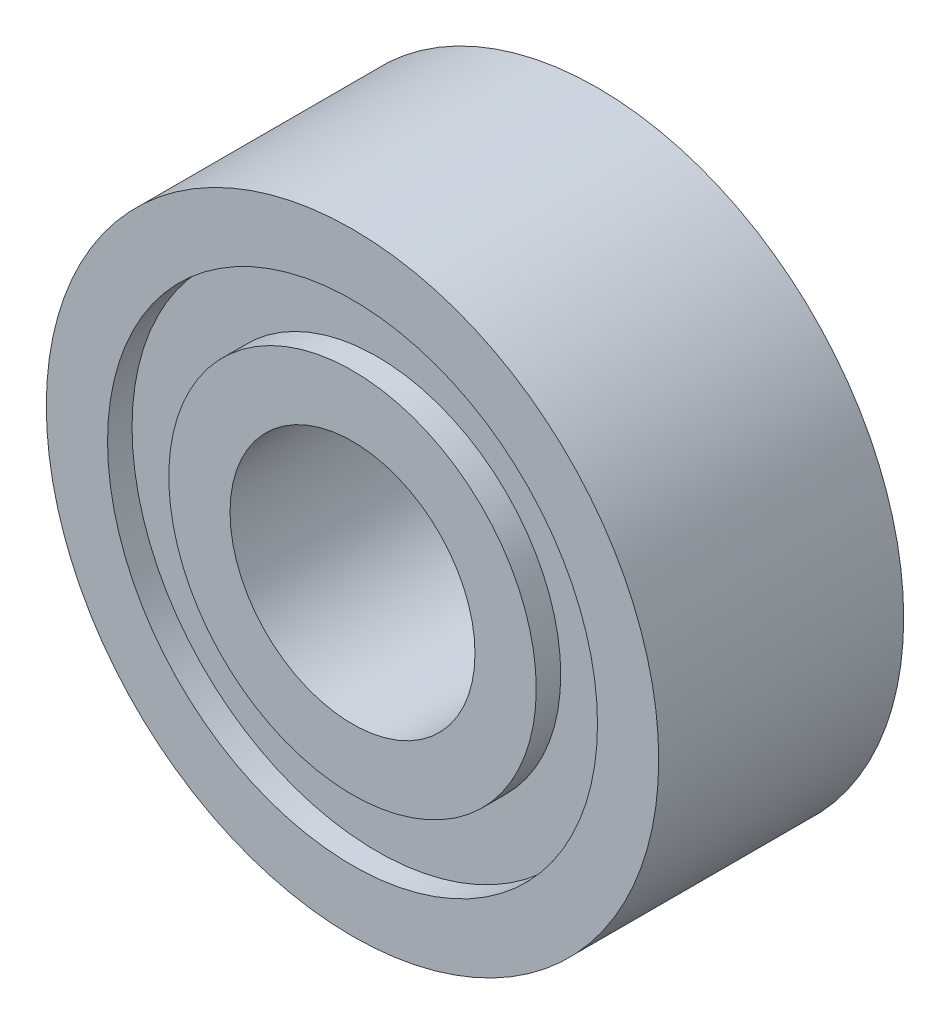
from build123d import *


with BuildPart() as part:
    # Sketch2 → Revolve1 (revolve)
    with BuildSketch(Plane(origin=(0, 0, 0), x_dir=(0, 0, -1), z_dir=(1, 0, 0))):
        Polygon((1.10919003, 2.5), (3.10919003, 2.5), (3.10919003, 2), (2.90919003, 2), (2.90919003, 1.5), (3.10919003, 1.5), (3.10919003, 1), (1.10919003, 1), (1.10919003, 1.5), (1.30919003, 1.5), (1.30919003, 2), (1.10919003, 2), align=None)
    revolve(axis=Axis((0, 0, 0), (0, 0, -1)))


solid = part.part
